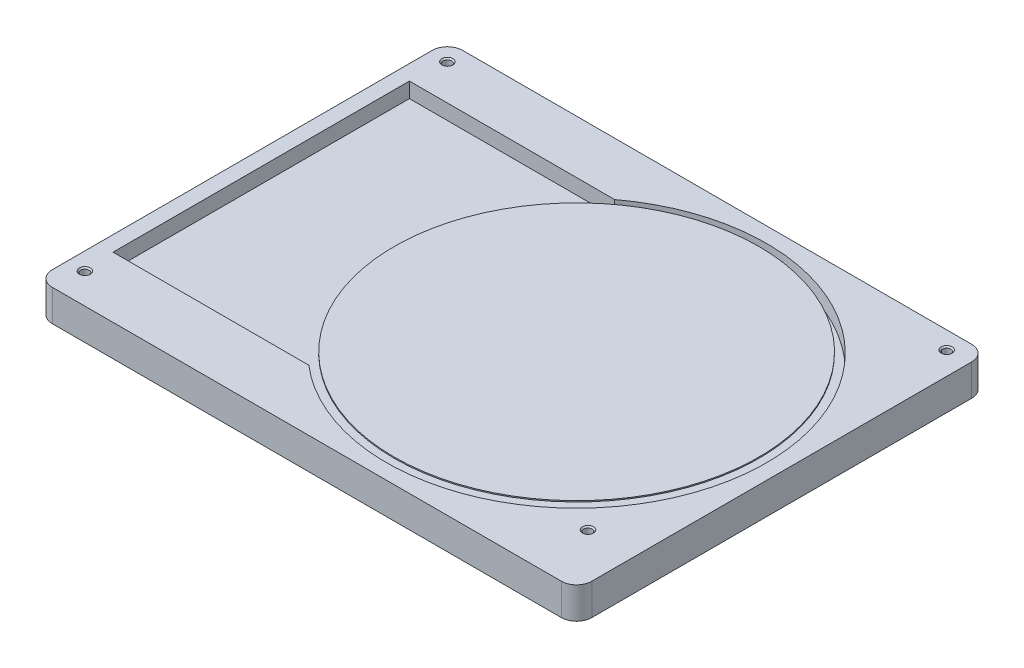
from build123d import *

# Parameters (mm, degrees)
SKETCH1_W                         = 71
SKETCH1_H                         = 54
BOSS_EXTRUDE1_DEPTH               = 4.15
CUT_EXTRUDE1_DEPTH                = 2
SKETCH4_R                         = 7.5
BOSS_EXTRUDE3_DEPTH               = 2
SKETCH5_R                         = 24
BOSS_EXTRUDE4_DEPTH               = 0.15
M1_4X0_3_TAPPED_HOLE1_D           = 1.1
M1_4X0_3_TAPPED_HOLE1_CSINK_D     = 1.45
M1_4X0_3_TAPPED_HOLE1_CSINK_ANGLE = 90
FILLET1_R                         = 2


with BuildPart() as part:
    # Sketch1 → Boss-Extrude1 (new body)
    with BuildSketch(Plane(origin=(0, 0, 0), x_dir=(1, 0, 0), z_dir=(0, 1, 0))):
        Rectangle(SKETCH1_W, SKETCH1_H)
    extrude(amount=BOSS_EXTRUDE1_DEPTH)

    # Sketch3 → Cut-Extrude1 (cut)
    with BuildSketch(Plane(origin=(0, 4.15, 0), x_dir=(1, 0, 0), z_dir=(0, 1, 0))):
        with BuildLine():
            Line((-6.5, 20), (-33.5, 20))
            Line((-33.5, 20), (-33.5, -19))
            Line((-33.5, -19), (-7.748076809, -19))
            ThreePointArc((-7.748076809, -19), (33.487208249, -0.799639875), (-6.5, 20))
        make_face()
    extrude(amount=-CUT_EXTRUDE1_DEPTH, mode=Mode.SUBTRACT)

    # Sketch4 → Boss-Extrude3 (add)
    with BuildSketch(Plane(origin=(0, 2.15, 0), x_dir=(1, 0, 0), z_dir=(0, 1, 0))):
        with Locations((8.5, 0)):
            Circle(SKETCH4_R)
    extrude(amount=BOSS_EXTRUDE3_DEPTH)

    # Sketch5 → Boss-Extrude4 (add)
    with BuildSketch(Plane(origin=(0, 4.15, 0), x_dir=(1, 0, 0), z_dir=(0, 1, 0))):
        with Locations((8.5, 0)):
            Circle(SKETCH5_R)
    extrude(amount=BOSS_EXTRUDE4_DEPTH)

    # M1.4x0.3 Tapped Hole1 (through all)
    with Locations(Plane(origin=(0, 4.15, 0), x_dir=(1, 0, 0), z_dir=(0, 1, 0))):
        with Locations((-33.2, 24.7), (-33.2, -23), (29.4, -19.4), (32.5, 24.7)):
            CounterSinkHole(M1_4X0_3_TAPPED_HOLE1_D / 2, M1_4X0_3_TAPPED_HOLE1_CSINK_D / 2, counter_sink_angle=M1_4X0_3_TAPPED_HOLE1_CSINK_ANGLE)

    # Fillet1
    fillet1_edges = [part.edges().sort_by_distance(p)[0] for p in [
        (35.5, 2.075, 27),
        (-35.5, 2.075, 27),
        (-35.5, 2.075, -27),
        (35.5, 2.075, -27),
    ]]
    fillet(fillet1_edges, radius=FILLET1_R)


solid = part.part
